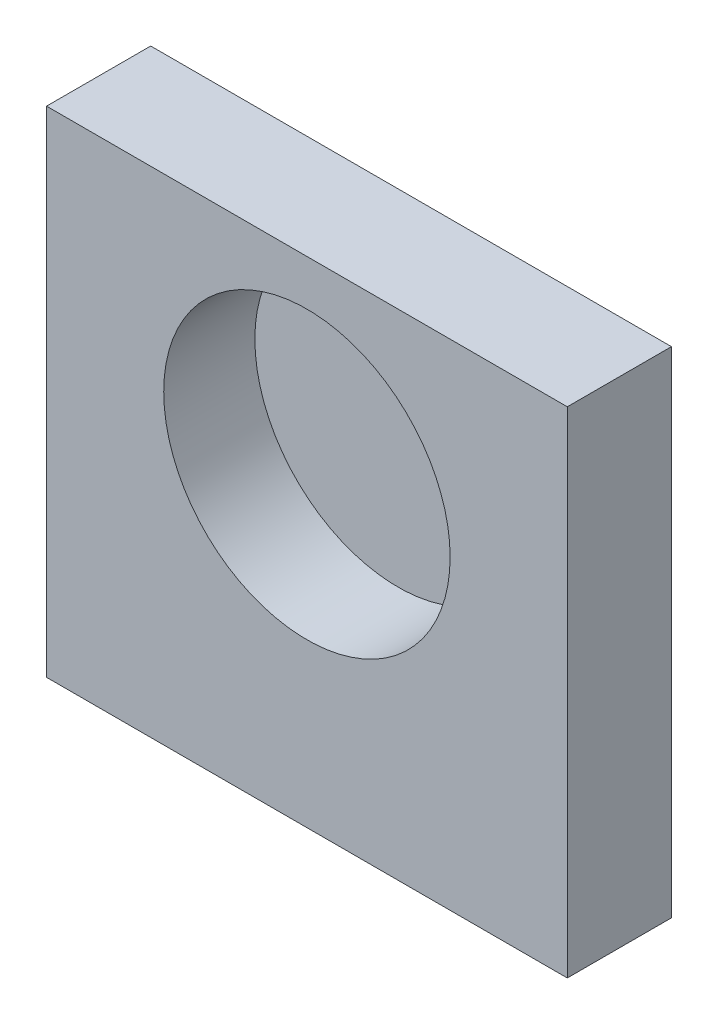
from build123d import *

# Parameters (mm, degrees)
ESBO_O1_W                                         = 40
ESBO_O1_H                                         = 38
RESSALTO_EXTRUS_O1_DEPTH                          = 8
ESBO_O2_R                                         = 11
CORTE_EXTRUS_O1_DEPTH                             = 7
FURO_ROSCADO_PARA_CONDU_TE_DE_M3X0_51_D           = 3.15
FURO_ROSCADO_PARA_CONDU_TE_DE_M3X0_51_DEPTH       = 10
FURO_ROSCADO_PARA_CONDU_TE_DE_M3X0_51_CSINK_D     = 3.766
FURO_ROSCADO_PARA_CONDU_TE_DE_M3X0_51_CSINK_ANGLE = 90
FURO_ROSCADO_PARA_CONDU_TE_DE_M3X0_51_TIP         = 0.946355475


with BuildPart() as part:
    # Esboço1 → Ressalto-extrusão1 (new body)
    with BuildSketch(Plane.XY):
        Rectangle(ESBO_O1_W, ESBO_O1_H)
    extrude(amount=RESSALTO_EXTRUS_O1_DEPTH)

    # Esboço2 → Corte-extrusão1 (cut)
    with BuildSketch(Plane.XY.offset(8)):
        with Locations((0, 4.5)):
            Circle(ESBO_O2_R)
    extrude(amount=-CORTE_EXTRUS_O1_DEPTH, mode=Mode.SUBTRACT)

    # Furo roscado para conduíte de M3x0.51
    with Locations(Plane(origin=(0, -19, 0), x_dir=(-1, 0, 0), z_dir=(0, -1, 0))):
        with Locations((-12, -4), (12, -4)):
            CounterSinkHole(FURO_ROSCADO_PARA_CONDU_TE_DE_M3X0_51_D / 2, FURO_ROSCADO_PARA_CONDU_TE_DE_M3X0_51_CSINK_D / 2, depth=FURO_ROSCADO_PARA_CONDU_TE_DE_M3X0_51_DEPTH, counter_sink_angle=FURO_ROSCADO_PARA_CONDU_TE_DE_M3X0_51_CSINK_ANGLE)
            with Locations((0, 0, -(FURO_ROSCADO_PARA_CONDU_TE_DE_M3X0_51_DEPTH + FURO_ROSCADO_PARA_CONDU_TE_DE_M3X0_51_TIP / 2))):  # 118° drill point
                Cone(0, FURO_ROSCADO_PARA_CONDU_TE_DE_M3X0_51_D / 2, FURO_ROSCADO_PARA_CONDU_TE_DE_M3X0_51_TIP, mode=Mode.SUBTRACT)


solid = part.part
